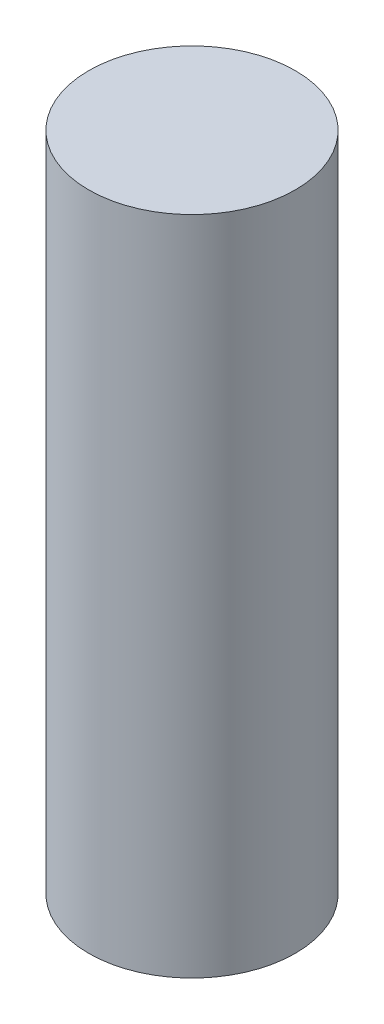
from build123d import *

# Parameters (mm, degrees)
SKETCH1_R           = 5
BOSS_EXTRUDE1_DEPTH = 32


with BuildPart() as part:
    # Sketch1 → Boss-Extrude1 (new body)
    with BuildSketch(Plane(origin=(0, 0, 0), x_dir=(1, 0, 0), z_dir=(0, 1, 0))):
        Circle(SKETCH1_R)
    extrude(amount=BOSS_EXTRUDE1_DEPTH)


solid = part.part
